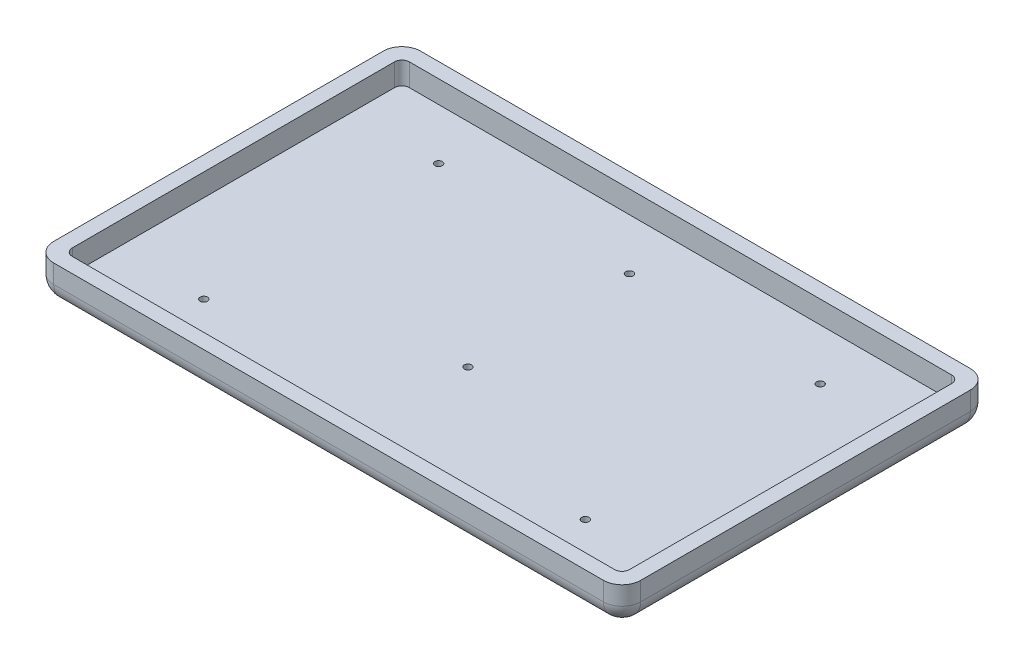
from build123d import *

# Parameters (mm, degrees)
SKETCH1_W             = 200
SKETCH1_H             = 125
BOSS_EXTRUDE1_DEPTH   = 12.7
SKETCH2_W             = 189.84
SKETCH2_H             = 114.84
CUT_EXTRUDE1_DEPTH    = 7.62
FILLET1_R             = 2.54
FILLET2_R             = 6.35
FILLET3_R             = 6.35
M3X0_5_TAPPED_HOLE1_D = 2.5


with BuildPart() as part:
    # Sketch1 → Boss-Extrude1 (new body)
    with BuildSketch(Plane(origin=(0, 0, 0), x_dir=(1, 0, 0), z_dir=(0, 1, 0))):
        Rectangle(SKETCH1_W, SKETCH1_H)
    extrude(amount=BOSS_EXTRUDE1_DEPTH)

    # Sketch2 → Cut-Extrude1 (cut)
    with BuildSketch(Plane(origin=(0, 12.7, 0), x_dir=(1, 0, 0), z_dir=(0, 1, 0))):
        Rectangle(SKETCH2_W, SKETCH2_H)
    extrude(amount=-CUT_EXTRUDE1_DEPTH, mode=Mode.SUBTRACT)

    # Fillet1
    fillet1_edges = [part.edges().sort_by_distance(p)[0] for p in [
        (94.92, 8.89, -57.42),
        (94.92, 8.89, 57.42),
        (-94.92, 8.89, 57.42),
        (-94.92, 8.89, -57.42),
    ]]
    fillet(fillet1_edges, radius=FILLET1_R)

    # Fillet2
    fillet2_edges = [part.edges().sort_by_distance(p)[0] for p in [
        (-100, 6.35, -62.5),
        (100, 6.35, -62.5),
        (100, 6.35, 62.5),
        (-100, 6.35, 62.5),
    ]]
    fillet(fillet2_edges, radius=FILLET2_R)

    # Fillet3
    fillet3_edges = [part.edges().sort_by_distance(p)[0] for p in [
        (0, 0, 62.5),
        (-100, 0, 0),
        (0, 0, -62.5),
        (100, 0, 0),
        (98.140128061, 0, 60.640128061),
        (98.140128061, 0, -60.640128061),
        (-98.140128061, 0, -60.640128061),
        (-98.140128061, 0, 60.640128061),
    ]]
    fillet(fillet3_edges, radius=FILLET3_R)

    # M3x0.5 Tapped Hole1 (through all)
    with Locations(Plane(origin=(0, 5.08, 0), x_dir=(1, 0, 0), z_dir=(0, 1, 0))):
        with Locations((0, -15), (-65, 40), (65, 40), (65, -40), (-65, -40), (0, 40)):
            Hole(M3X0_5_TAPPED_HOLE1_D / 2)


solid = part.part
